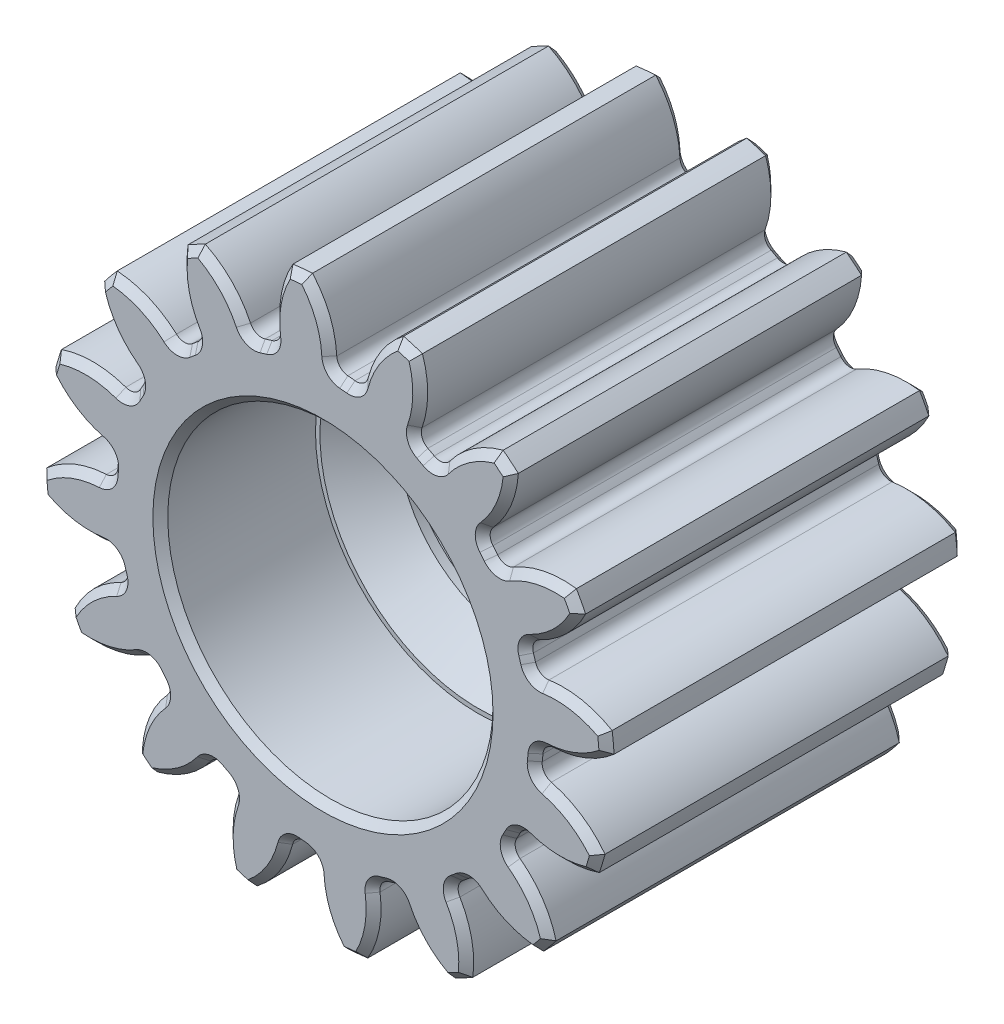
from build123d import *

# Parameters (mm, degrees)
SKETCH3_R          = 9.525
GEARBODY_DEPTH     = 12
TOOTHCUT_DEPTH     = 13
CIRPATTERN1_COUNT  = 16
BOREDIA_R          = 4
BORE_DEPTH         = 12700
SKETCH5_R          = 5.45
CUT_EXTRUDE2_DEPTH = 5.2
SKETCH6_R          = 5.45
CUT_EXTRUDE3_DEPTH = 5.2
CHAMFER1_SIZE      = 0.25
CHAMFER2_SIZE      = 1.3


with BuildPart() as part:
    # Sketch3 → gearBody (new body)
    with BuildSketch(Plane.XY):
        Circle(SKETCH3_R)
    extrude(amount=GEARBODY_DEPTH)

    # Sketch2 → toothCut (cut, through all)
    with BuildSketch(Plane.XY):
        with BuildLine():
            ThreePointArc((7.098007151, -0.825654225), (7.110962737, -0.705421411), (7.121881853, -0.584986575))
            ThreePointArc((7.121881853, -0.584986575), (7.244448998, -0.326070493), (7.507360795, -0.212326792))
            ThreePointArc((7.507360795, -0.212326792), (8.942776091, 0.19912633), (10.04426967, 1.20730421))
            ThreePointArc((10.04426967, 1.20730421), (10.067153141, -0.99868128), (9.611304734, -3.157175632))
            ThreePointArc((9.611304734, -3.157175632), (8.729356694, -1.952236464), (7.40275638, -1.266785992))
            ThreePointArc((7.40275638, -1.266785992), (7.167316076, -1.103604788), (7.098007151, -0.825654225))
        make_face()
    toothcut = extrude(amount=TOOTHCUT_DEPTH, mode=Mode.SUBTRACT)

    # CirPattern1: toothCut ×16 about axis
    cirpattern1_axis = Axis((0, 0, 0), (0, 0, 1))
    for i in range(1, CIRPATTERN1_COUNT):
        add(toothcut.rotate(cirpattern1_axis, i * 360 / CIRPATTERN1_COUNT), mode=Mode.SUBTRACT)

    # boreDia → bore (cut, symmetric)
    with BuildSketch(Plane.XY):
        Circle(BOREDIA_R)
    extrude(amount=BORE_DEPTH, both=True, mode=Mode.SUBTRACT)

    # Sketch5 → Cut-Extrude2 (cut)
    with BuildSketch(Plane(origin=(0, 0, 0), x_dir=(-1, 0, 0), z_dir=(0, 0, -1))):
        Circle(SKETCH5_R)
    extrude(amount=-CUT_EXTRUDE2_DEPTH, mode=Mode.SUBTRACT)

    # Sketch6 → Cut-Extrude3 (cut)
    with BuildSketch(Plane.XY.offset(12)):
        Circle(SKETCH6_R)
    extrude(amount=-CUT_EXTRUDE3_DEPTH, mode=Mode.SUBTRACT)

    # Chamfer1
    chamfer1_edges = [part.edges().sort_by_distance(p)[0] for p in [
        (8.575735729, 0.022864998, 12),
        (7.244448998, -0.326070493, 12),
        (7.110962737, -0.705421411, 12),
        (7.167316076, -1.103604788, 12),
        (8.404100183, -1.707297929, 12),
        (-7.931696773, 3.26066748, 12),
        (8.404100183, -1.707297929, 0),
        (-6.568216378, 3.073580463, 12),
        (-6.299719843, 3.372972031, 12),
        (-6.199405357, 3.762410992, 12),
        (-7.111021517, 4.793447517, 12),
        (-6.080128883, 6.047792893, 12),
        (-4.892032356, 5.35316567, 12),
        (-4.529401709, 5.527018235, 12),
        (-4.287691371, 5.848424229, 12),
        (-4.735354286, 7.149838172, 12),
        (-3.302916488, 7.914196661, 12),
        (-2.471080753, 6.817779929, 12),
        (-2.069523225, 6.839626016, 12),
        (-1.723215241, 7.044067893, 12),
        (-1.638772291, 8.41773078, 12),
        (-0.022864998, 8.575735729, 12),
        (0.326070493, 7.244448998, 12),
        (0.705421411, 7.110962737, 12),
        (1.103604788, 7.167316076, 12),
        (1.707297929, 8.404100183, 12),
        (3.26066748, 7.931696773, 12),
        (7.244448998, -0.326070493, 0),
        (3.073580463, 6.568216378, 12),
        (3.372972031, 6.299719843, 12),
        (3.762410992, 6.199405357, 12),
        (4.793447517, 7.111021517, 12),
        (6.047792893, 6.080128883, 12),
        (5.35316567, 4.892032356, 12),
        (5.527018235, 4.529401709, 12),
        (5.848424229, 4.287691371, 12),
        (7.149838172, 4.735354286, 12),
        (7.914196661, 3.302916488, 12),
        (6.817779929, 2.471080753, 12),
        (6.839626016, 2.069523225, 12),
        (7.044067893, 1.723215241, 12),
        (7.110962737, -0.705421411, 0),
        (8.41773078, 1.638772291, 12),
        (7.931696773, -3.26066748, 12),
        (6.568216378, -3.073580463, 12),
        (6.299719843, -3.372972031, 12),
        (6.199405357, -3.762410992, 12),
        (7.111021517, -4.793447517, 12),
        (6.080128883, -6.047792893, 12),
        (4.892032356, -5.35316567, 12),
        (4.529401709, -5.527018235, 12),
        (4.287691371, -5.848424229, 12),
        (4.735354286, -7.149838172, 12),
        (3.302916488, -7.914196661, 12),
        (2.471080753, -6.817779929, 12),
        (2.069523225, -6.839626016, 12),
        (7.167316076, -1.103604788, 0),
        (1.723215241, -7.044067893, 12),
        (1.638772291, -8.41773078, 12),
        (0.022864998, -8.575735729, 12),
        (-0.326070493, -7.244448998, 12),
        (-0.705421411, -7.110962737, 12),
        (-1.103604788, -7.167316076, 12),
        (-1.707297929, -8.404100183, 12),
        (-3.26066748, -7.931696773, 12),
        (-3.073580463, -6.568216378, 12),
        (-3.372972031, -6.299719843, 12),
        (-3.762410992, -6.199405357, 12),
        (-4.793447517, -7.111021517, 12),
        (-6.047792893, -6.080128883, 12),
        (-5.35316567, -4.892032356, 12),
        (-5.527018235, -4.529401709, 12),
        (-5.848424229, -4.287691371, 12),
        (-7.149838172, -4.735354286, 12),
        (-7.914196661, -3.302916488, 12),
        (-6.817779929, -2.471080753, 12),
        (-6.839626016, -2.069523225, 12),
        (-7.044067893, -1.723215241, 12),
        (-8.41773078, -1.638772291, 12),
        (-8.575735729, -0.022864998, 12),
        (-7.244448998, 0.326070493, 12),
        (-7.110962737, 0.705421411, 12),
        (-7.167316076, 1.103604788, 12),
        (-8.404100183, 1.707297929, 12),
        (7.111021517, -4.793447517, 0),
        (4.735354286, -7.149838172, 0),
        (1.638772291, -8.41773078, 0),
        (-1.707297929, -8.404100183, 0),
        (-4.793447517, -7.111021517, 0),
        (-7.149838172, -4.735354286, 0),
        (-8.41773078, -1.638772291, 0),
        (-8.404100183, 1.707297929, 0),
        (-7.111021517, 4.793447517, 0),
        (-4.735354286, 7.149838172, 0),
        (-1.638772291, 8.41773078, 0),
        (1.707297929, 8.404100183, 0),
        (4.793447517, 7.111021517, 0),
        (7.149838172, 4.735354286, 0),
        (8.41773078, 1.638772291, 0),
        (6.568216378, -3.073580463, 0),
        (6.299719843, -3.372972031, 0),
        (6.199405357, -3.762410992, 0),
        (4.892032356, -5.35316567, 0),
        (4.529401709, -5.527018235, 0),
        (4.287691371, -5.848424229, 0),
        (2.471080753, -6.817779929, 0),
        (2.069523225, -6.839626016, 0),
        (1.723215241, -7.044067893, 0),
        (-0.326070493, -7.244448998, 0),
        (-0.705421411, -7.110962737, 0),
        (-1.103604788, -7.167316076, 0),
        (9.479789137, 0.926942782, 0),
        (-3.073580463, -6.568216378, 0),
        (-3.372972031, -6.299719843, 0),
        (-3.762410992, -6.199405357, 0),
        (-5.35316567, -4.892032356, 0),
        (-5.527018235, -4.529401709, 0),
        (-5.848424229, -4.287691371, 0),
        (-6.817779929, -2.471080753, 0),
        (-6.839626016, -2.069523225, 0),
        (-7.044067893, -1.723215241, 0),
        (-7.244448998, 0.326070493, 0),
        (-7.110962737, 0.705421411, 0),
        (-7.167316076, 1.103604788, 0),
        (-6.568216378, 3.073580463, 0),
        (-6.299719843, 3.372972031, 0),
        (-6.199405357, 3.762410992, 0),
        (-4.892032356, 5.35316567, 0),
        (-4.529401709, 5.527018235, 0),
        (-4.287691371, 5.848424229, 0),
        (-2.471080753, 6.817779929, 0),
        (-2.069523225, 6.839626016, 0),
        (-1.723215241, 7.044067893, 0),
        (0.326070493, 7.244448998, 0),
        (0.705421411, 7.110962737, 0),
        (1.103604788, 7.167316076, 0),
        (3.073580463, 6.568216378, 0),
        (3.372972031, 6.299719843, 0),
        (3.762410992, 6.199405357, 0),
        (5.35316567, 4.892032356, 0),
        (5.527018235, 4.529401709, 0),
        (5.848424229, 4.287691371, 0),
        (6.817779929, 2.471080753, 0),
        (6.839626016, 2.069523225, 0),
        (7.044067893, 1.723215241, 0),
        (8.40345751, 4.484141709, 0),
        (6.047775656, 7.35867071, 0),
        (2.77137478, 9.112908802, 0),
        (-0.926942782, 9.479789137, 0),
        (-4.484141709, 8.40345751, 0),
        (-7.35867071, 6.047775656, 0),
        (-9.112908802, 2.77137478, 0),
        (-9.479789137, -0.926942782, 0),
        (-8.40345751, -4.484141709, 0),
        (-6.047775656, -7.35867071, 0),
        (-2.77137478, -9.112908802, 0),
        (0.926942782, -9.479789137, 0),
        (4.484141709, -8.40345751, 0),
        (5.45, 0, 0),
        (7.35867071, -6.047775656, 0),
        (-5.45, 0, 12),
        (9.112908802, -2.77137478, 0),
        (9.479789137, 0.926942782, 12),
        (7.914196661, 3.302916488, 0),
        (6.047792893, 6.080128883, 0),
        (3.26066748, 7.931696773, 0),
        (-0.022864998, 8.575735729, 0),
        (-3.302916488, 7.914196661, 0),
        (-6.080128883, 6.047792893, 0),
        (-7.931696773, 3.26066748, 0),
        (-8.575735729, -0.022864998, 0),
        (8.575735729, 0.022864998, 0),
        (-7.914196661, -3.302916488, 0),
        (-6.047792893, -6.080128883, 0),
        (-3.26066748, -7.931696773, 0),
        (0.022864998, -8.575735729, 0),
        (3.302916488, -7.914196661, 0),
        (6.080128883, -6.047792893, 0),
        (7.931696773, -3.26066748, 0),
        (8.40345751, 4.484141709, 12),
        (6.047775656, 7.35867071, 12),
        (2.77137478, 9.112908802, 12),
        (-0.926942782, 9.479789137, 12),
        (-4.484141709, 8.40345751, 12),
        (-7.35867071, 6.047775656, 12),
        (-9.112908802, 2.77137478, 12),
        (-9.479789137, -0.926942782, 12),
        (-8.40345751, -4.484141709, 12),
        (-6.047775656, -7.35867071, 12),
        (-2.77137478, -9.112908802, 12),
        (0.926942782, -9.479789137, 12),
        (4.484141709, -8.40345751, 12),
        (7.35867071, -6.047775656, 12),
        (9.112908802, -2.77137478, 12),
    ]]
    chamfer(chamfer1_edges, length=CHAMFER1_SIZE)

    # Chamfer2
    chamfer2_edges = [part.edges().sort_by_distance(p)[0] for p in [
        (-4, 0, 6.8),
    ]]
    chamfer(chamfer2_edges, length=CHAMFER2_SIZE)


solid = part.part
